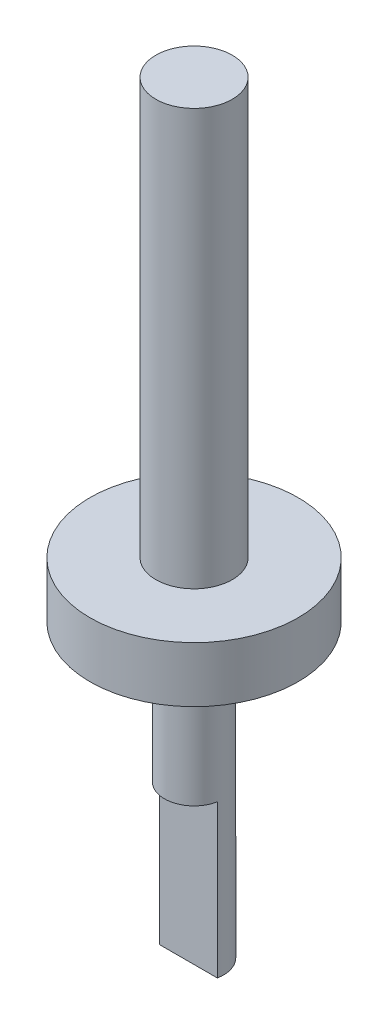
from build123d import *

# Parameters (mm, degrees)
BOSS_EXTRUDE1_DEPTH = 27.94
BOSS_EXTRUDE3_DEPTH = 25.4
SKETCH5_R           = 19.06504515
BOSS_EXTRUDE4_DEPTH = 10.16
SKETCH6_R           = 7
BOSS_EXTRUDE5_DEPTH = 76.2


with BuildPart() as part:
    # Sketch1 → Boss-Extrude1 (new body)
    with BuildSketch(Plane(origin=(0, 0, 0), x_dir=(1, 0, 0), z_dir=(0, 1, 0))):
        with BuildLine():
            Line((-5.3, -3.217204022), (5.3, -3.217204022))
            ThreePointArc((5.3, -3.217204022), (0, 3.217204022), (-5.3, -3.217204022))
        make_face()
    extrude(amount=BOSS_EXTRUDE1_DEPTH)

    # Sketch4 → Boss-Extrude3 (add)
    with BuildSketch(Plane(origin=(0, 27.94, 0), x_dir=(1, 0, 0), z_dir=(0, 1, 0))):
        with BuildLine():
            Line((5.3, -3.217204022), (-5.3, -3.217204022))
            ThreePointArc((-5.3, -3.217204022), (0, -7.582795978), (5.3, -3.217204022))
        make_face()
        with BuildLine():
            Line((-5.3, -3.217204022), (5.3, -3.217204022))
            ThreePointArc((5.3, -3.217204022), (0, 3.217204022), (-5.3, -3.217204022))
        make_face()
    extrude(amount=BOSS_EXTRUDE3_DEPTH)

    # Sketch5 → Boss-Extrude4 (add)
    with BuildSketch(Plane(origin=(0, 53.34, 0), x_dir=(1, 0, 0), z_dir=(0, 1, 0))):
        with Locations((0, -2.182795978)):
            Circle(SKETCH5_R)
    extrude(amount=BOSS_EXTRUDE4_DEPTH)

    # Sketch6 → Boss-Extrude5 (add)
    with BuildSketch(Plane(origin=(0, 63.5, 0), x_dir=(1, 0, 0), z_dir=(0, 1, 0))):
        with Locations((0, -2.182795978)):
            Circle(SKETCH6_R)
    extrude(amount=BOSS_EXTRUDE5_DEPTH)


solid = part.part
